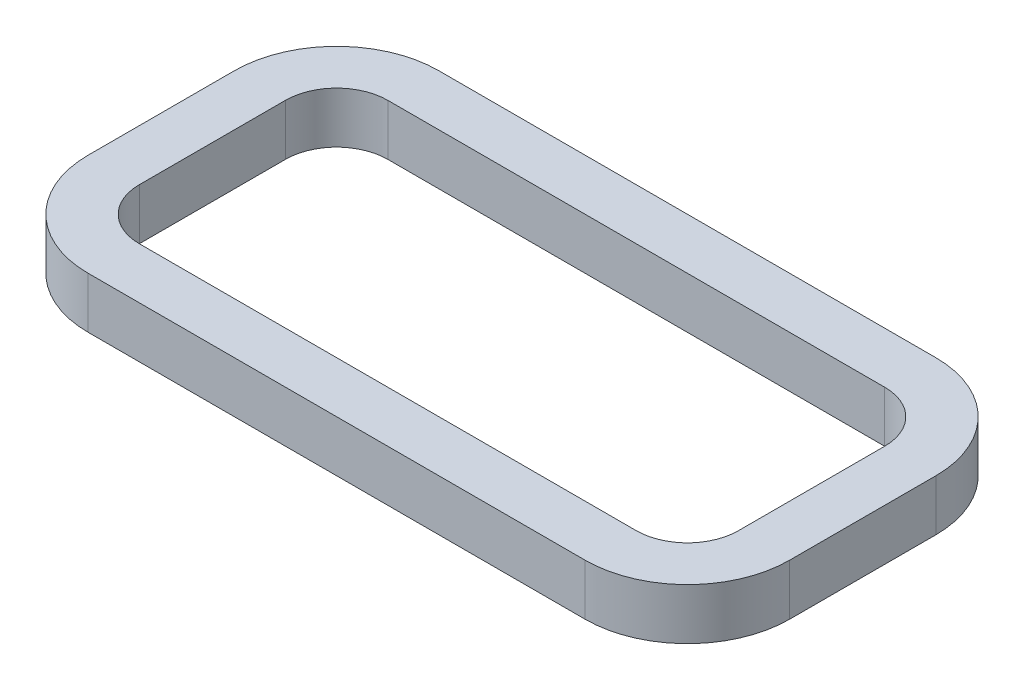
from build123d import *

# Parameters (mm, degrees)
EXTRUDE_THIN1_DEPTH = 22.225


with BuildPart() as part:
    # Sketch1 → Extrude-Thin1 (new body)
    with BuildSketch(Plane(origin=(0, 0, 0), x_dir=(1, 0, 0), z_dir=(0, 1, 0))):
        with BuildLine():
            Line((-107.95, 76.2), (107.95, 76.2))
            ThreePointArc((107.95, 76.2), (139.380896424, 63.180896424), (152.4, 31.75))
            Line((152.4, 31.75), (152.4, -31.75))
            ThreePointArc((152.4, -31.75), (139.380896424, -63.180896424), (107.95, -76.2))
            Line((107.95, -76.2), (-107.95, -76.2))
            ThreePointArc((-107.95, -76.2), (-139.380896424, -63.180896424), (-152.4, -31.75))
            Line((-152.4, -31.75), (-152.4, 31.75))
            ThreePointArc((-152.4, 31.75), (-139.380896424, 63.180896424), (-107.95, 76.2))
        make_face()
        with BuildLine():
            Line((-107.95, 53.975), (107.95, 53.975))
            ThreePointArc((107.95, 53.975), (123.665448212, 47.465448212), (130.175, 31.75))
            Line((130.175, 31.75), (130.175, -31.75))
            ThreePointArc((130.175, -31.75), (123.665448212, -47.465448212), (107.95, -53.975))
            Line((107.95, -53.975), (-107.95, -53.975))
            ThreePointArc((-107.95, -53.975), (-123.665448212, -47.465448212), (-130.175, -31.75))
            Line((-130.175, -31.75), (-130.175, 31.75))
            ThreePointArc((-130.175, 31.75), (-123.665448212, 47.465448212), (-107.95, 53.975))
        make_face(mode=Mode.SUBTRACT)
    extrude(amount=EXTRUDE_THIN1_DEPTH)


solid = part.part
